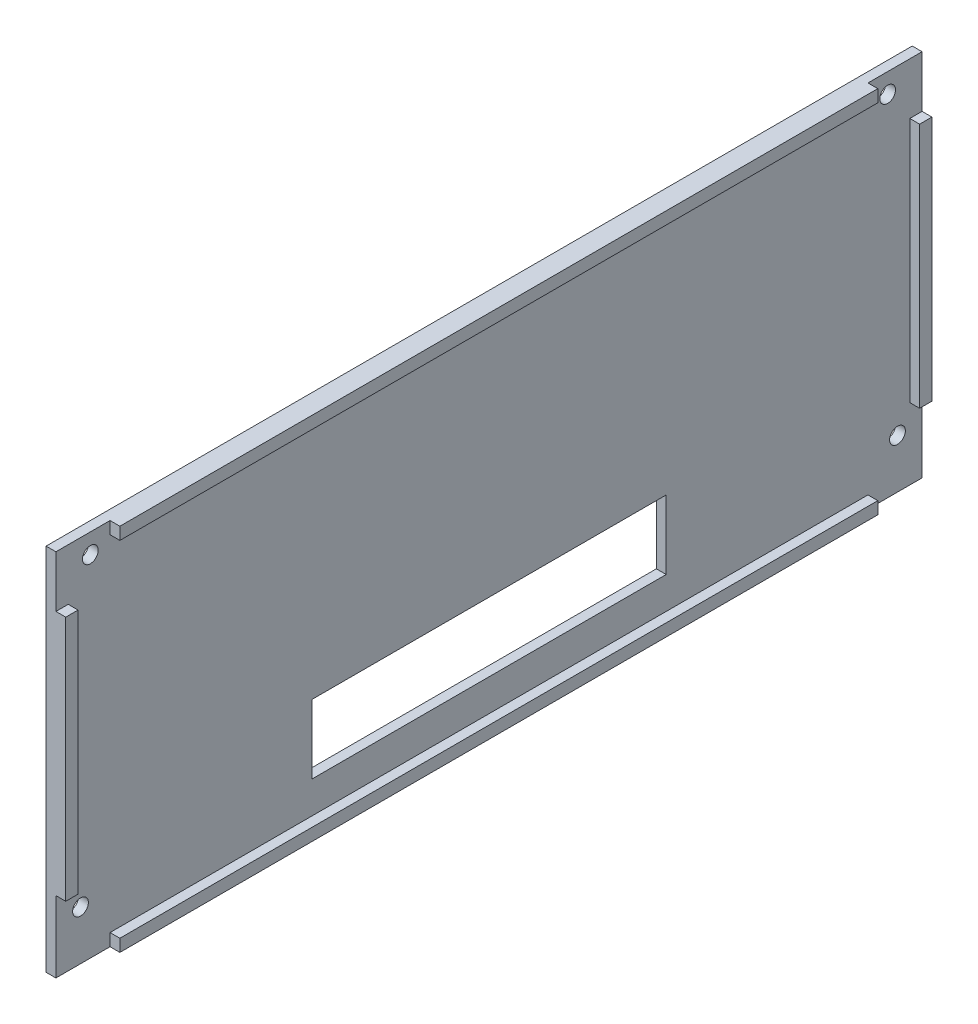
from build123d import *

# Parameters (mm, degrees)
SKETCH1_W           = 176
SKETCH1_H           = 75
SKETCH1_R           = 1.6
BOSS_EXTRUDE1_DEPTH = 2
SKETCH2_W           = 72
SKETCH2_H           = 14
CUT_EXTRUDE1_DEPTH  = 2
SKETCH3_W           = 154
SKETCH3_H           = 2.5
BOSS_EXTRUDE2_DEPTH = 2
SKETCH4_W           = 2.5
SKETCH4_H           = 50
BOSS_EXTRUDE3_DEPTH = 2


with BuildPart() as part:
    # Sketch1 → Boss-Extrude1 (new body)
    with BuildSketch(Plane(origin=(0, 0, 0), x_dir=(0, 0, -1), z_dir=(1, 0, 0))):
        Rectangle(SKETCH1_W, SKETCH1_H)
        with Locations((-81, 33.5)):
            Circle(SKETCH1_R, mode=Mode.SUBTRACT)
        with Locations((81, 33.5)):
            Circle(SKETCH1_R, mode=Mode.SUBTRACT)
        with Locations((-83, -27.5)):
            Circle(SKETCH1_R, mode=Mode.SUBTRACT)
        with Locations((83, -27.5)):
            Circle(SKETCH1_R, mode=Mode.SUBTRACT)
    extrude(amount=BOSS_EXTRUDE1_DEPTH)

    # Sketch2 → Cut-Extrude1 (cut)
    with BuildSketch(Plane(origin=(2, 0, 0), x_dir=(0, 0, -1), z_dir=(1, 0, 0))):
        with Locations((0, -21.5)):
            Rectangle(SKETCH2_W, SKETCH2_H)
    extrude(amount=-CUT_EXTRUDE1_DEPTH, mode=Mode.SUBTRACT)

    # Sketch3 → Boss-Extrude2 (add)
    with BuildSketch(Plane(origin=(2, 0, 0), x_dir=(0, 0, -1), z_dir=(1, 0, 0))):
        with Locations((0, -36.25)):
            Rectangle(SKETCH3_W, SKETCH3_H)
        with Locations((0, 36.25)):
            Rectangle(SKETCH3_W, SKETCH3_H)
    extrude(amount=BOSS_EXTRUDE2_DEPTH)

    # Sketch4 → Boss-Extrude3 (add)
    with BuildSketch(Plane(origin=(2, 0, 0), x_dir=(0, 0, -1), z_dir=(1, 0, 0))):
        with Locations((-86.75, 2)):
            Rectangle(SKETCH4_W, SKETCH4_H)
        with Locations((86.75, 2)):
            Rectangle(SKETCH4_W, SKETCH4_H)
    extrude(amount=BOSS_EXTRUDE3_DEPTH)


solid = part.part
